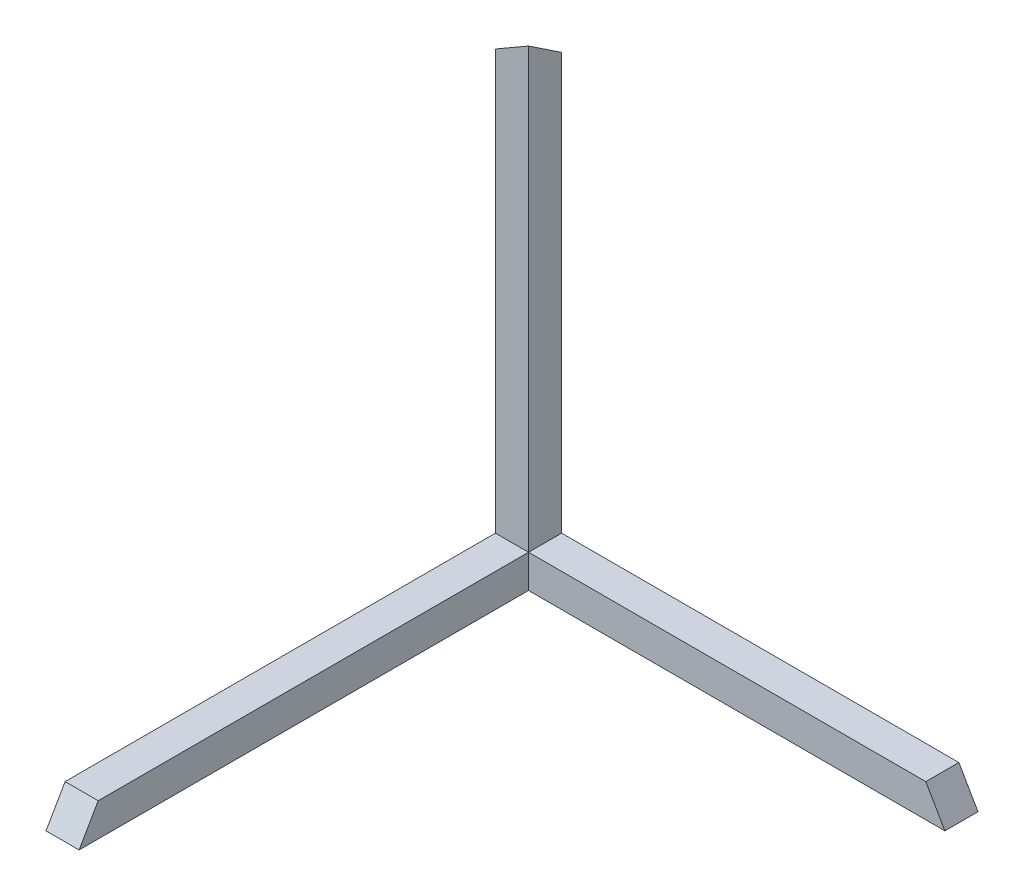
from build123d import *

# Parameters (mm, degrees)
SKETCH1_W           = 5
SKETCH1_H           = 65
BOSS_EXTRUDE1_DEPTH = 5
SKETCH2_W           = 65
SKETCH2_H           = 5
BOSS_EXTRUDE3_DEPTH = 5
SKETCH4_W           = 65
SKETCH4_H           = 5
BOSS_EXTRUDE4_DEPTH = 5
DRAFT3_ANGLE        = 30
DRAFT7_ANGLE        = 30
DRAFT8_ANGLE        = 30
DRAFT9_ANGLE        = 30


with BuildPart() as part:
    # Sketch1 → Boss-Extrude1 (new body)
    with BuildSketch(Plane.XY):
        with Locations((-75.007440829, -10.132080835)):
            Rectangle(SKETCH1_W, SKETCH1_H)
    extrude(amount=BOSS_EXTRUDE1_DEPTH)

    # Sketch2 → Boss-Extrude3 (add)
    with BuildSketch(Plane.ZY.offset(77.507440829)):
        with Locations((37.5, -40.132080835)):
            Rectangle(SKETCH2_W, SKETCH2_H)
    extrude(amount=-BOSS_EXTRUDE3_DEPTH)

    # Sketch4 → Boss-Extrude4 (add)
    with BuildSketch(Plane(origin=(0, -37.632080835, 0), x_dir=(1, 0, 0), z_dir=(0, 1, 0))):
        with Locations((-45.007440829, -2.5)):
            Rectangle(SKETCH4_W, SKETCH4_H)
    extrude(amount=-BOSS_EXTRUDE4_DEPTH)

    # Draft3
    draft3_faces = [part.faces().sort_by_distance(p)[0] for p in [
        (-12.507440829, -40.132080835, 2.5),
    ]]
    draft(draft3_faces, Plane.ZX.offset(-37.632080835), DRAFT3_ANGLE)

    # Draft7
    draft7_faces = [part.faces().sort_by_distance(p)[0] for p in [
        (-75.007440829, -40.132080835, 70),
    ]]
    draft(draft7_faces, Plane(origin=(-72.507440829, -37.632080835, 5), x_dir=(0, 0, 1), z_dir=(0, 1, 0)), DRAFT7_ANGLE)

    # Draft8
    draft8_faces = [part.faces().sort_by_distance(p)[0] for p in [
        (-75.007440829, 22.367919165, 2.5),
    ]]
    draft(draft8_faces, Plane(origin=(-77.507440829, 22.367919165, 5), x_dir=(0, 0, -1), z_dir=(-1, 0, 0)), DRAFT8_ANGLE)

    # Draft9
    draft9_faces = [part.faces().sort_by_distance(p)[0] for p in [
        (-75.007440829, 23.811294838, 2.5),
    ]]
    draft(draft9_faces, Plane(origin=(0, 0, 0), x_dir=(-1, 0, 0), z_dir=(0, 0, -1)), DRAFT9_ANGLE)


solid = part.part
